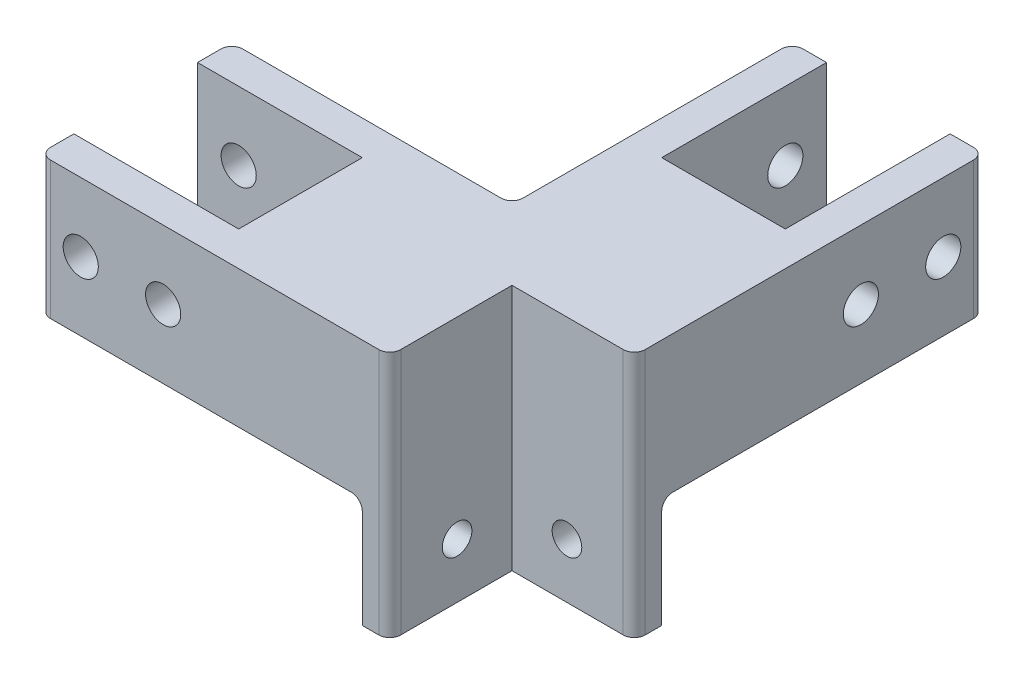
from build123d import *

# Parameters (mm, degrees)
EXTRUDE_1_DEPTH     = 25
SKETCH_2_R          = 3.2
CUT_EXTRUDE_1_DEPTH = 35
SKETCH_3_R          = 3.2
CUT_EXTRUDE_2_DEPTH = 35
SKETCH_5_W          = 22.25
SKETCH_5_H          = 22.25
CUT_EXTRUDE_4_DEPTH = 25
EXTRUDE_2_DEPTH     = 20
SKETCH_7_R          = 2.7
CUT_EXTRUDE_5_DEPTH = 5
SKETCH_8_R          = 2.7
CUT_EXTRUDE_6_DEPTH = 5
FILLET_1_R          = 2


with BuildPart() as part:
    # 스케치1 → 보스-돌출1 (new body)
    with BuildSketch(Plane(origin=(0, 0, 0), x_dir=(1, 0, 0), z_dir=(0, 1, 0))):
        Polygon((-17.5, 68.5), (-11.25, 68.5), (-11.25, 38.5), (11.25, 38.5), (11.25, 68.5), (17.5, 68.5), (17.5, -17.5), (-68.5, -17.5), (-68.5, -11.25), (-38.5, -11.25), (-38.5, 11.25), (-68.5, 11.25), (-68.5, 17.5), (-17.5, 17.5), align=None)
    extrude(amount=EXTRUDE_1_DEPTH)

    # 스케치2 → 컷-돌출1 (cut)
    with BuildSketch(Plane(origin=(17.5, 0, 0), x_dir=(0, 0, -1), z_dir=(1, 0, 0))):
        with Locations((61, 12.5)):
            Circle(SKETCH_2_R)
        with Locations((46, 12.5)):
            Circle(SKETCH_2_R)
    extrude(amount=-CUT_EXTRUDE_1_DEPTH, mode=Mode.SUBTRACT)

    # 스케치3 → 컷-돌출2 (cut)
    with BuildSketch(Plane.XY.offset(17.5)):
        with Locations((-61, 12.5)):
            Circle(SKETCH_3_R)
        with Locations((-46, 12.5)):
            Circle(SKETCH_3_R)
    extrude(amount=-CUT_EXTRUDE_2_DEPTH, mode=Mode.SUBTRACT)

    # 스케치5 → 컷-돌출4 (cut)
    with BuildSketch(Plane(origin=(0, 25, 0), x_dir=(1, 0, 0), z_dir=(0, 1, 0))):
        with Locations((6.375, -6.375)):
            Rectangle(SKETCH_5_W, SKETCH_5_H)
    extrude(amount=-CUT_EXTRUDE_4_DEPTH, mode=Mode.SUBTRACT)

    # 스케치6 → 보스-돌출2 (add)
    with BuildSketch(Plane.XZ):
        Polygon((-9.75, 17.5), (-4.75, 17.5), (-4.75, -4.75), (17.5, -4.75), (17.5, -9.75), (-9.75, -9.75), align=None)
    extrude(amount=EXTRUDE_2_DEPTH)

    # 스케치7 → 컷-돌출5 (cut)
    with BuildSketch(Plane(origin=(-4.75, 0, 0), x_dir=(0, 0, -1), z_dir=(1, 0, 0))):
        with Locations((-5.25, -10)):
            Circle(SKETCH_7_R)
    extrude(amount=-CUT_EXTRUDE_5_DEPTH, mode=Mode.SUBTRACT)

    # 스케치8 → 컷-돌출6 (cut)
    with BuildSketch(Plane.XY.offset(-4.75)):
        with Locations((5.25, -10)):
            Circle(SKETCH_8_R)
    extrude(amount=-CUT_EXTRUDE_6_DEPTH, mode=Mode.SUBTRACT)

    # 필렛1
    fillet_1_edges = [part.edges().sort_by_distance(p)[0] for p in [
        (-17.5, 12.5, -68.5),
        (17.5, 12.5, -68.5),
        (-68.5, 12.5, 17.5),
        (-68.5, 12.5, -17.5),
        (-17.5, 12.5, -17.5),
        (-4.75, 2.5, 17.5),
        (17.5, 2.5, -4.75),
        (-9.75, 0, 3.875),
        (3.875, 0, -9.75),
        (-9.75, -10, -9.75),
    ]]
    fillet(fillet_1_edges, radius=FILLET_1_R)


solid = part.part
